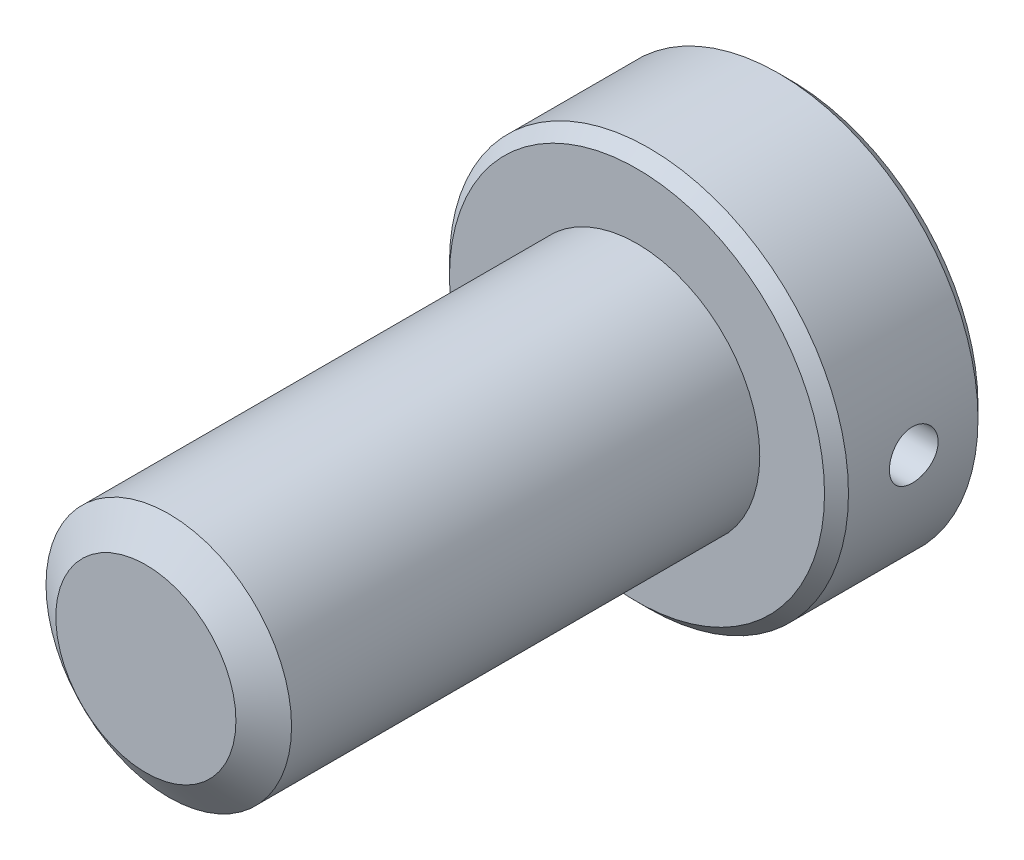
from build123d import *

# Parameters (mm, degrees)
SKETCH1_R               = 4
EXTRUDE1_DEPTH          = 16
SKETCH6_R               = 6.5
EXTRUDE2_DEPTH          = 5
CUT_EXTRUDE1_DEPTH      = 4.5
CHAMFER1_SIZE           = 0.39
CUT_EXTRUDE3_DEPTH      = 23.923786773
CUT_EXTRUDE3_DEPTH_BACK = 23.923786773
SKETCH11_R              = 0.79375


with BuildPart() as part:
    # Sketch1 → Extrude1 (new body)
    with BuildSketch(Plane.XY):
        Circle(SKETCH1_R)
    extrude(amount=-EXTRUDE1_DEPTH)

    # Sketch4 → Cut-Revolve1 (revolve, cut)
    with BuildSketch(Plane(origin=(0, 0, 0), x_dir=(0, 0, -1), z_dir=(1, 0, 0))):
        Polygon((0.746350386, 4), (0, 2.934101184), (0, 4), align=None)
    revolve(axis=Axis((0, 0, 0), (0, 0, -1)), mode=Mode.SUBTRACT)

    # Sketch6 → Extrude2 (add)
    with BuildSketch(Plane(origin=(0, 0, -16), x_dir=(-1, 0, 0), z_dir=(0, 0, -1))):
        Circle(SKETCH6_R)
    extrude(amount=EXTRUDE2_DEPTH)

    # Sketch7 → Cut-Extrude1 (cut)
    with BuildSketch(Plane(origin=(0, 0, -21), x_dir=(-1, 0, 0), z_dir=(0, 0, -1))):
        Polygon((0, 3.464101615), (-3, 1.732050808), (-3, -1.732050808), (0, -3.464101615), (3, -1.732050808), (3, 1.732050808), align=None)
    extrude(amount=-CUT_EXTRUDE1_DEPTH, mode=Mode.SUBTRACT)

    # Cut-Extrude2 cone 1 section (through the dimple's axis) → Cut-Extrude2 (revolve, cut)
    with BuildSketch(Plane(origin=(0, 0, -21), x_dir=(0, 1, 0), z_dir=(1, 0, 0))):
        Polygon((0, 0), (3.464101615, 0), (0, 3.464101615), align=None)
    revolve(axis=Axis((0, 0, -21), (0, 0, 1)), mode=Mode.SUBTRACT)

    # Chamfer1
    chamfer1_edges = [part.edges().sort_by_distance(p)[0] for p in [
        (6.5, 0, -21),
        (6.5, 0, -16),
    ]]
    chamfer(chamfer1_edges, length=CHAMFER1_SIZE)

    # Sketch11 → Cut-Extrude3 (cut, two sides: drawn at the far end of the back side and taken through both)
    with BuildSketch(Plane(origin=(0, 0, 0), x_dir=(0, -1, 0), z_dir=(1, 0, 0)).offset(-CUT_EXTRUDE3_DEPTH_BACK)):
        with Locations((0, 18.517949192)):
            Circle(SKETCH11_R)
    extrude(amount=CUT_EXTRUDE3_DEPTH + CUT_EXTRUDE3_DEPTH_BACK, mode=Mode.SUBTRACT)


solid = part.part
